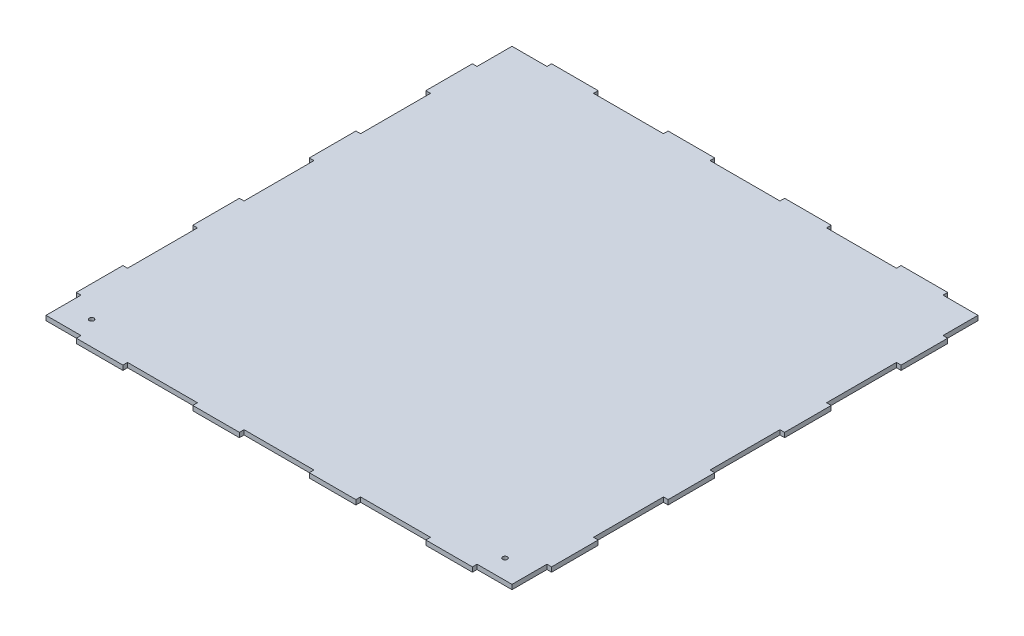
from build123d import *

# Parameters (mm, degrees)
BOSS_EXTRUDE1_DEPTH = 8
SKETCH2_R           = 4
CUT_EXTRUDE1_DEPTH  = 10


with BuildPart() as part:
    # Sketch1 → Boss-Extrude1 (new body)
    with BuildSketch(Plane(origin=(0, 0, 0), x_dir=(1, 0, 0), z_dir=(0, 1, 0))):
        Polygon((340, 408), (260, 408), (260, 400), (140, 400), (140, 408), (60, 408), (60, 400), (-60, 400), (-60, 408), (-140, 408), (-140, 400), (-260, 400), (-260, 408), (-340, 408), (-340, 400), (-400, 400), (-400, 340), (-408, 340), (-408, 260), (-400, 260), (-400, 140), (-408, 140), (-408, 60), (-400, 60), (-400, -60), (-408, -60), (-408, -140), (-400, -140), (-400, -260), (-408, -260), (-408, -340), (-400, -340), (-400, -400), (-340, -400), (-340, -408), (-260, -408), (-260, -400), (-140, -400), (-140, -408), (-60, -408), (-60, -400), (60, -400), (60, -408), (140, -408), (140, -400), (260, -400), (260, -408), (340, -408), (340, -400), (400, -400), (400, -340), (408, -340), (408, -260), (400, -260), (400, -140), (408, -140), (408, -60), (400, -60), (400, 60), (408, 60), (408, 140), (400, 140), (400, 260), (408, 260), (408, 340), (400, 340), (400, 400), (340, 400), align=None)
    extrude(amount=BOSS_EXTRUDE1_DEPTH)

    # Sketch2 → Cut-Extrude1 (cut)
    with BuildSketch(Plane(origin=(0, 8, 0), x_dir=(1, 0, 0), z_dir=(0, 1, 0))):
        with Locations((-354.85, -366.85)):
            Circle(SKETCH2_R)
        with Locations((354.85, -366.85)):
            Circle(SKETCH2_R)
    extrude(amount=-CUT_EXTRUDE1_DEPTH, mode=Mode.SUBTRACT)


solid = part.part
